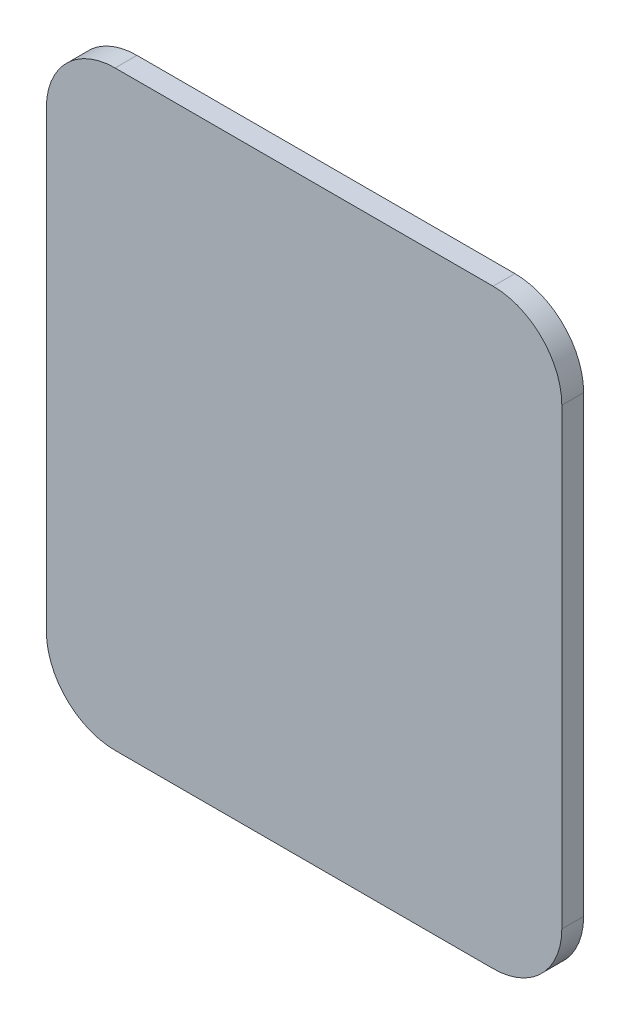
from build123d import *

# Parameters (mm, degrees)
BOSS_EXTRUDE1_DEPTH = 6.35


with BuildPart() as part:
    # Sketch1 → Boss-Extrude1 (new body)
    with BuildSketch(Plane.XY):
        with BuildLine():
            Line((-55, 0), (55, 0))
            ThreePointArc((55, 0), (69.142135624, 5.857864376), (75, 20))
            Line((75, 20), (75, 152))
            ThreePointArc((75, 152), (69.142135624, 166.142135624), (55, 172))
            Line((55, 172), (-55, 172))
            ThreePointArc((-55, 172), (-69.142135624, 166.142135624), (-75, 152))
            Line((-75, 152), (-75, 20))
            ThreePointArc((-75, 20), (-69.142135624, 5.857864376), (-55, 0))
        make_face()
    extrude(amount=BOSS_EXTRUDE1_DEPTH)


solid = part.part
